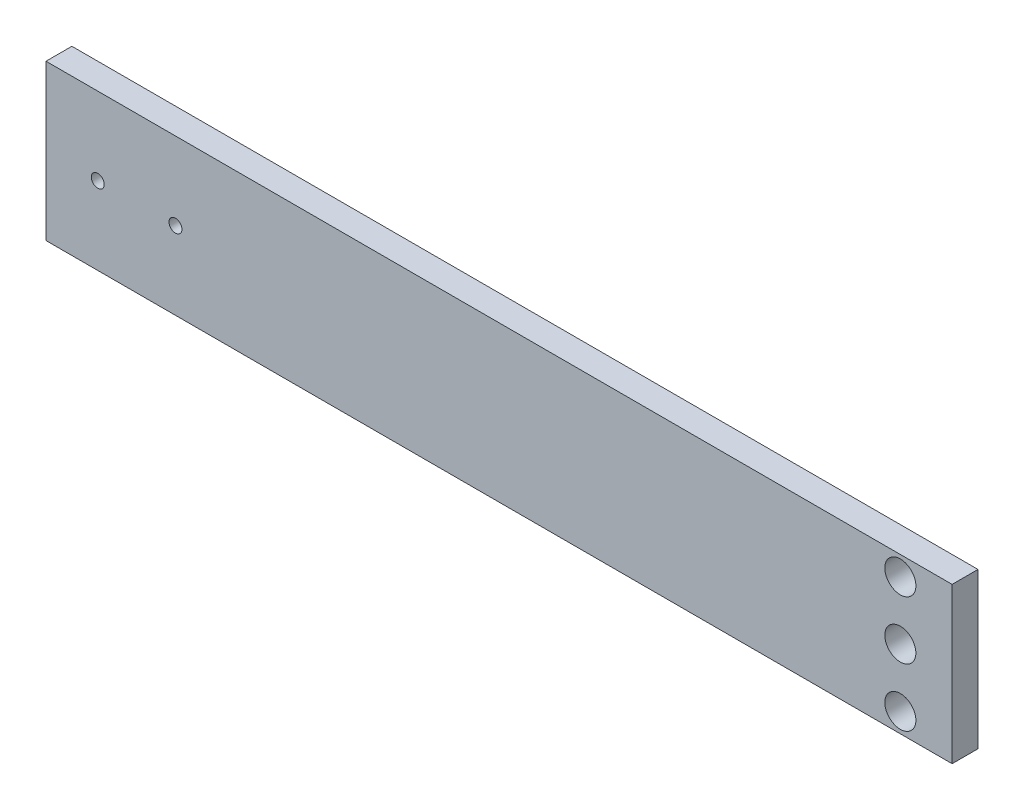
from build123d import *

# Parameters (mm, degrees)
SKETCH_1_W             = 350
SKETCH_1_H             = 60
EXTRUDE_1_DEPTH        = 10
HOLE_WIZARD_M6_1_D     = 5
HOLE_WIZARD_M6_1_DEPTH = 20
HOLE_WIZARD_M6_1_TIP   = 1.502151548
MM_1_D                 = 12
MM_1_DEPTH             = 20
MM_1_TIP               = 3.605163714


with BuildPart() as part:
    # 草图1 → 凸台-拉伸1 (new body)
    with BuildSketch(Plane.XY):
        Rectangle(SKETCH_1_W, SKETCH_1_H)
    extrude(amount=EXTRUDE_1_DEPTH)

    # M6 螺纹孔1
    with Locations(Plane(origin=(-155, 0, 10), x_dir=(1, 0, 0), z_dir=(0, 0, 1))):
        with Locations((0, 0), (30, 0)):
            Hole(HOLE_WIZARD_M6_1_D / 2, depth=HOLE_WIZARD_M6_1_DEPTH)
            with Locations((0, 0, -(HOLE_WIZARD_M6_1_DEPTH + HOLE_WIZARD_M6_1_TIP / 2))):  # 118° drill point
                Cone(0, HOLE_WIZARD_M6_1_D / 2, HOLE_WIZARD_M6_1_TIP, mode=Mode.SUBTRACT)

    # 大小mm 暗销槽口1
    with Locations(Plane.XY.offset(10)):
        with Locations((155, -22.5), (155, 0), (155, 22.5)):
            Hole(MM_1_D / 2, depth=MM_1_DEPTH)
            with Locations((0, 0, -(MM_1_DEPTH + MM_1_TIP / 2))):  # 118° drill point
                Cone(0, MM_1_D / 2, MM_1_TIP, mode=Mode.SUBTRACT)


solid = part.part
